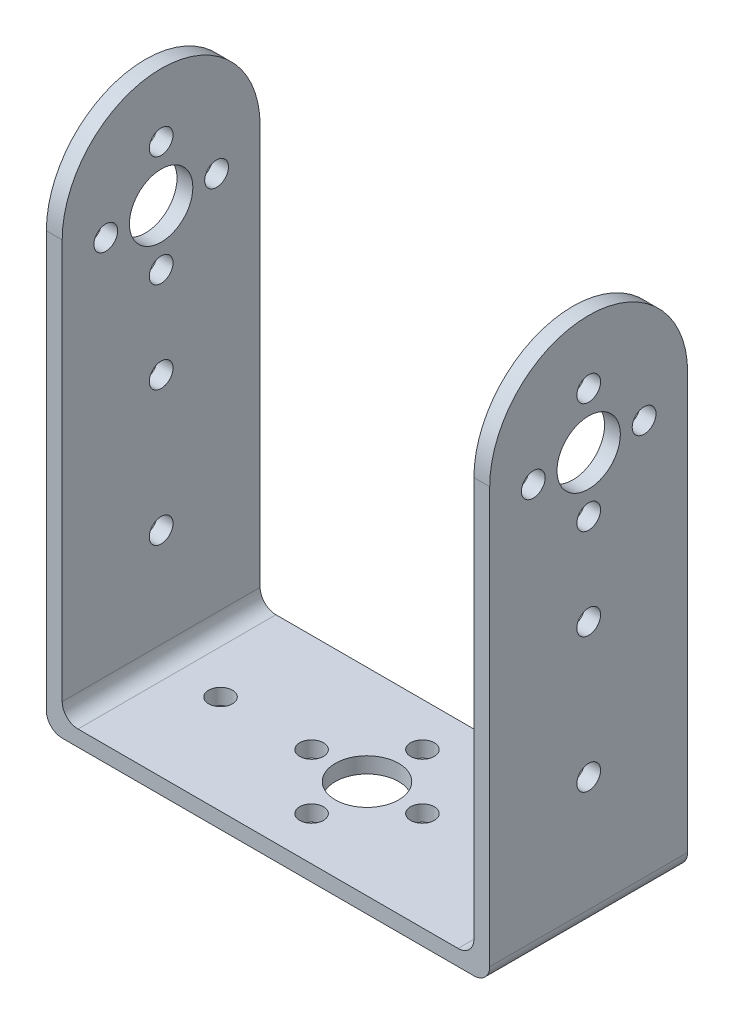
from build123d import *

# Parameters (mm, degrees)
SKETCH1_W           = 56
SKETCH1_H           = 25
BOSS_EXTRUDE1_DEPTH = 2
SKETCH1_3_W         = 2
SKETCH1_3_H         = 25
BOSS_EXTRUDE2_DEPTH = 65
FILLET4_R           = 2
SKETCH2_R           = 1.5
SKETCH2_R_2         = 4
CUT_EXTRUDE1_DEPTH  = 65
SKETCH3_R           = 4
SKETCH3_R_2         = 1.5
CUT_EXTRUDE2_DEPTH  = 65


with BuildPart() as part:
    # Sketch1 → Boss-Extrude1 (new body)
    with BuildSketch(Plane(origin=(0, 0, 0), x_dir=(1, 0, 0), z_dir=(0, 1, 0))):
        Rectangle(SKETCH1_W, SKETCH1_H)
    extrude(amount=-BOSS_EXTRUDE1_DEPTH)

    # Sketch1_3 → Boss-Extrude2 (add)
    with BuildSketch(Plane(origin=(0, 0, 0), x_dir=(1, 0, 0), z_dir=(0, 1, 0))):
        with Locations((-27, 0)):
            Rectangle(SKETCH1_3_W, SKETCH1_3_H)
        with Locations((27, 0)):
            Rectangle(SKETCH1_3_W, SKETCH1_3_H)
    extrude(amount=BOSS_EXTRUDE2_DEPTH)

    # Fillet4
    fillet4_edges = [part.edges().sort_by_distance(p)[0] for p in [
        (28, -2, 0),
        (26, 0, 0),
        (-28, -2, 0),
        (-26, 0, 0),
    ]]
    fillet(fillet4_edges, radius=FILLET4_R)

    # Sketch2 → Cut-Extrude1 (cut)
    with BuildSketch(Plane(origin=(28, 0, 0), x_dir=(0, 0, -1), z_dir=(1, 0, 0))):
        with BuildLine():
            Line((12.5, 65), (0, 65))
            ThreePointArc((0, 65), (8.838834765, 61.338834765), (12.5, 52.5))
            Line((12.5, 52.5), (12.5, 65))
        make_face()
        with BuildLine():
            Line((-12.5, 65), (-12.5, 52.5))
            ThreePointArc((-12.5, 52.5), (-8.838834765, 61.338834765), (0, 65))
            Line((0, 65), (-12.5, 65))
        make_face()
        with Locations((0, 14.5)):
            Circle(SKETCH2_R)
        with Locations((0, 31.5)):
            Circle(SKETCH2_R)
        with Locations((0, 50)):
            Circle(SKETCH2_R_2)
        with Locations((0, 57)):
            Circle(SKETCH2_R)
        with Locations((7, 50)):
            Circle(SKETCH2_R)
        with Locations((0, 43)):
            Circle(SKETCH2_R)
        with Locations((-7, 50)):
            Circle(SKETCH2_R)
    extrude(amount=-CUT_EXTRUDE1_DEPTH, mode=Mode.SUBTRACT)

    # Sketch3 → Cut-Extrude2 (cut)
    with BuildSketch(Plane(origin=(0, 0, 0), x_dir=(1, 0, 0), z_dir=(0, 1, 0))):
        Circle(SKETCH3_R)
        with Locations((0, 7)):
            Circle(SKETCH3_R_2)
        with Locations((7, 0)):
            Circle(SKETCH3_R_2)
        with Locations((0, -7)):
            Circle(SKETCH3_R_2)
        with Locations((-7, 0)):
            Circle(SKETCH3_R_2)
        with Locations((-18.5, 0)):
            Circle(SKETCH3_R_2)
        with Locations((18.5, 0)):
            Circle(SKETCH3_R_2)
    extrude(amount=-CUT_EXTRUDE2_DEPTH, mode=Mode.SUBTRACT)


solid = part.part
